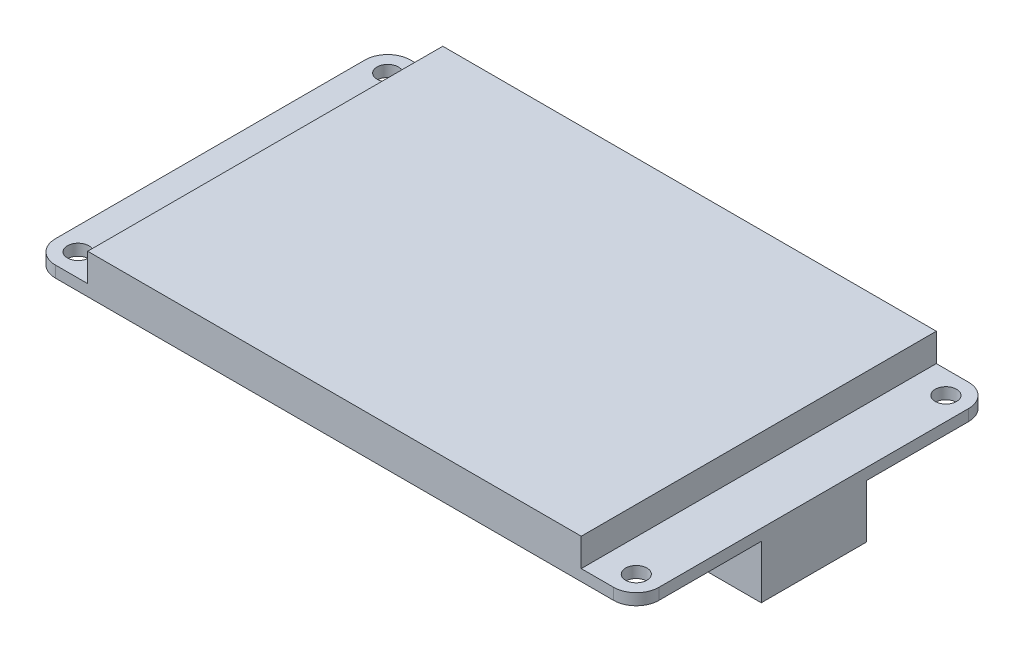
from build123d import *

# Parameters (mm, degrees)
SKETCH1_W           = 85
SKETCH1_H           = 50
BOSS_EXTRUDE1_DEPTH = 5.55
SKETCH2_W           = 7.75
SKETCH2_H           = 50
CUT_EXTRUDE1_DEPTH  = 3.95
SKETCH3_R           = 1.5
CUT_EXTRUDE2_DEPTH  = 2.6
SKETCH4_W           = 5.700401694
SKETCH4_H           = 17.101205084
BOSS_EXTRUDE2_DEPTH = 3
SKETCH5_W           = 8.5
SKETCH5_H           = 14.8
BOSS_EXTRUDE3_DEPTH = 7.5


with BuildPart() as part:
    # Sketch1 → Boss-Extrude1 (new body)
    with BuildSketch(Plane(origin=(0, 0, 0), x_dir=(1, 0, 0), z_dir=(0, 1, 0))):
        with Locations((42.5, 25)):
            Rectangle(SKETCH1_W, SKETCH1_H)
    extrude(amount=BOSS_EXTRUDE1_DEPTH)

    # Sketch2 → Cut-Extrude1 (cut)
    with BuildSketch(Plane(origin=(0, 5.55, 0), x_dir=(1, 0, 0), z_dir=(0, 1, 0))):
        with Locations((3.875, 25)):
            Rectangle(SKETCH2_W, SKETCH2_H)
        with Locations((81.125, 25)):
            Rectangle(SKETCH2_W, SKETCH2_H)
    extrude(amount=-CUT_EXTRUDE1_DEPTH, mode=Mode.SUBTRACT)

    # Sketch3 → Cut-Extrude2 (cut, through all)
    with BuildSketch(Plane(origin=(0, 1.6, 0), x_dir=(1, 0, 0), z_dir=(0, 1, 0))):
        with Locations((3.2, 46.8)):
            Circle(SKETCH3_R)
        with Locations((3.2, 3.2)):
            Circle(SKETCH3_R)
        with Locations((81.8, 3.2)):
            Circle(SKETCH3_R)
        with Locations((81.8, 46.8)):
            Circle(SKETCH3_R)
        with BuildLine():
            Line((0, 46.8), (0, 50))
            Line((0, 50), (3.2, 50))
            ThreePointArc((3.2, 50), (0.9372583, 49.0627417), (0, 46.8))
        make_face()
        with BuildLine():
            Line((0, 0), (3.2, 0))
            ThreePointArc((3.2, 0), (0.9372583, 0.9372583), (0, 3.2))
            Line((0, 3.2), (0, 0))
        make_face()
        with BuildLine():
            Line((85, 3.2), (85, 0))
            Line((85, 0), (81.8, 0))
            ThreePointArc((81.8, 0), (84.0627417, 0.9372583), (85, 3.2))
        make_face()
        with BuildLine():
            Line((85, 50), (81.8, 50))
            ThreePointArc((81.8, 50), (84.0627417, 49.0627417), (85, 46.8))
            Line((85, 46.8), (85, 50))
        make_face()
    extrude(amount=-CUT_EXTRUDE2_DEPTH, mode=Mode.SUBTRACT)

    # Sketch4 → Boss-Extrude2 (add)
    with BuildSketch(Plane.XZ):
        with Locations((33.858914892, -11.880027846)):
            Rectangle(SKETCH4_W, SKETCH4_H)
    extrude(amount=BOSS_EXTRUDE2_DEPTH)

    # Sketch5 → Boss-Extrude3 (add)
    with BuildSketch(Plane.XZ):
        with Locations((80.75, -25)):
            Rectangle(SKETCH5_W, SKETCH5_H)
    extrude(amount=BOSS_EXTRUDE3_DEPTH)


solid = part.part
